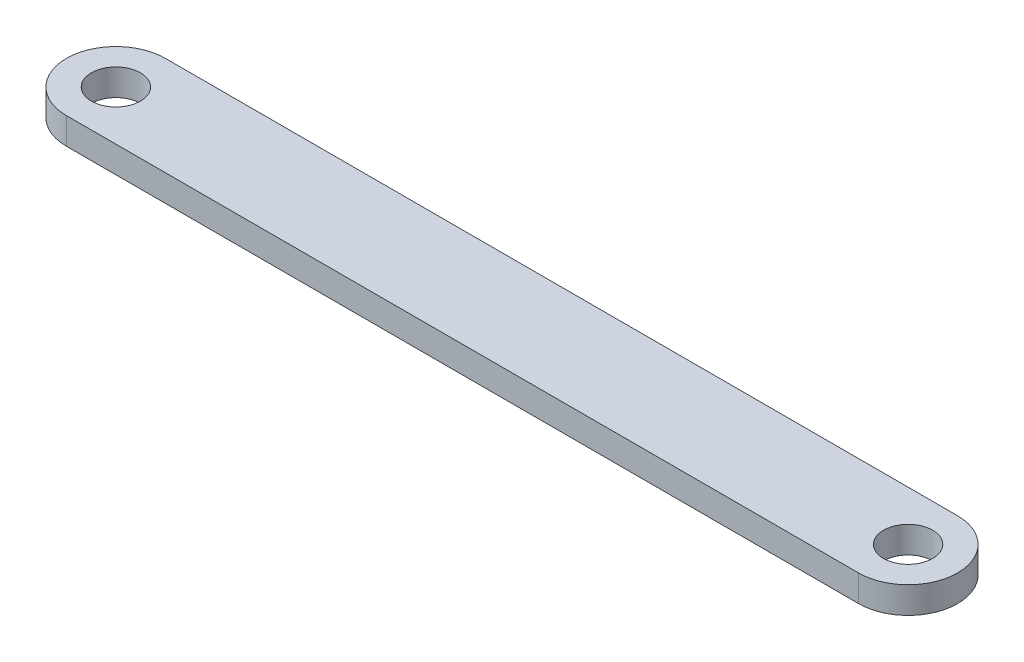
from build123d import *

# Parameters (mm, degrees)
SKETCH1_R           = 6
BOSS_EXTRUDE1_DEPTH = 6.5


with BuildPart() as part:
    # Sketch1 → Boss-Extrude1 (new body)
    with BuildSketch(Plane(origin=(0, 0, 0), x_dir=(1, 0, 0), z_dir=(0, 1, 0))):
        with BuildLine():
            Line((0, 12.106579693), (193.705275083, 12.106579693))
            ThreePointArc((193.705275083, 12.106579693), (205.811854776, 0), (193.705275083, -12.106579693))
            Line((193.705275083, -12.106579693), (0, -12.106579693))
            ThreePointArc((0, -12.106579693), (-12.106579693, 0), (0, 12.106579693))
        make_face()
        Circle(SKETCH1_R, mode=Mode.SUBTRACT)
        with Locations((193.705275083, 0)):
            Circle(SKETCH1_R, mode=Mode.SUBTRACT)
    extrude(amount=BOSS_EXTRUDE1_DEPTH)


solid = part.part
